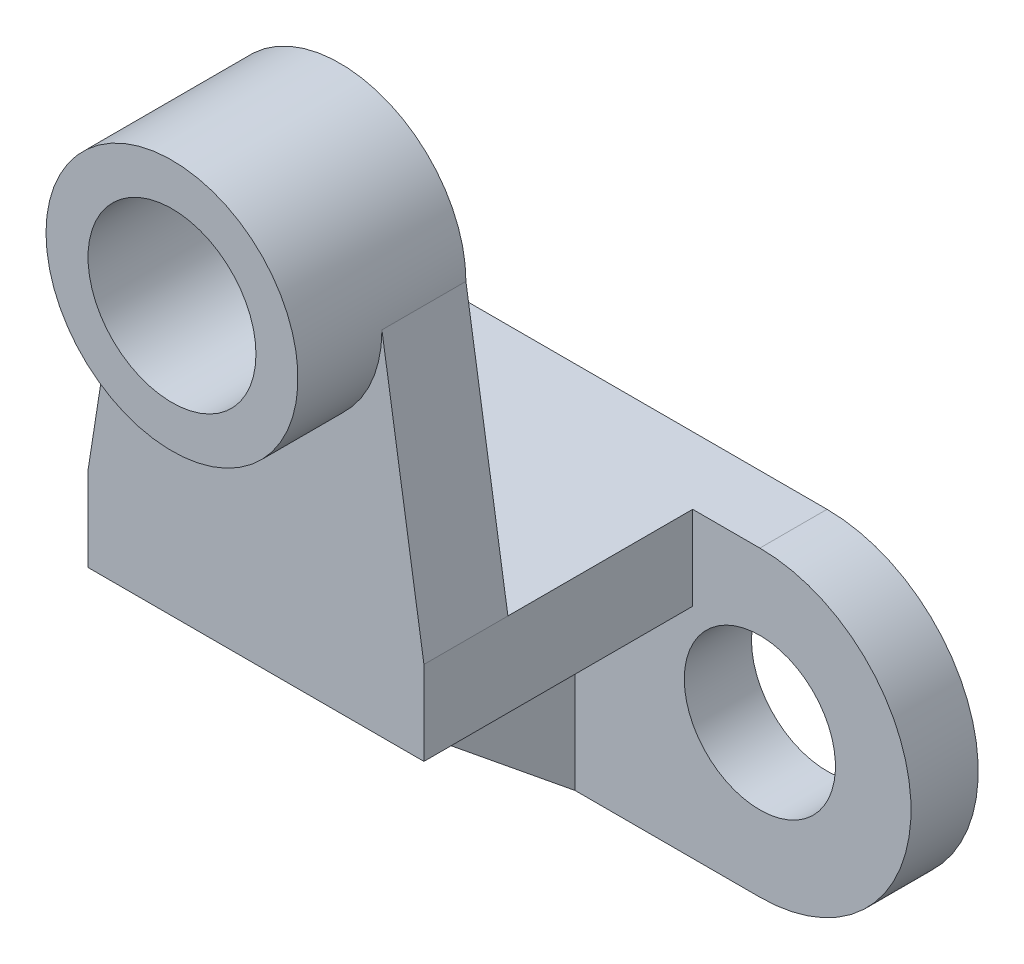
from build123d import *

# Parameters (mm, degrees)
BOSS_EXTRUDE2_DEPTH = 8
SKETCH5_R           = 9
CUT_EXTRUDE2_DEPTH  = 8
BOSS_EXTRUDE3_DEPTH = 32
CUT_EXTRUDE3_DEPTH  = 12
SKETCH8_W           = 40
SKETCH8_H           = 10
BOSS_EXTRUDE4_DEPTH = 32
SKETCH10_R          = 15
BOSS_EXTRUDE5_DEPTH = 20
CUT_EXTRUDE4_DEPTH  = 10
CUT_EXTRUDE5_DEPTH  = 10
SKETCH14_R          = 10
CUT_EXTRUDE6_DEPTH  = 20


with BuildPart() as part:
    # Sketch1 → Boss-Extrude2 (new body)
    with BuildSketch(Plane.XY):
        with BuildLine():
            Line((0, 0), (56, 0))
            ThreePointArc((56, 0), (74, 18), (56, 36))
            Line((56, 36), (0, 36))
            ThreePointArc((0, 36), (-18, 18), (0, 0))
        make_face()
    extrude(amount=BOSS_EXTRUDE2_DEPTH)

    # Sketch5 → Cut-Extrude2 (cut)
    with BuildSketch(Plane(origin=(0, 0, 0), x_dir=(-1, 0, 0), z_dir=(0, 0, -1))):
        with Locations((0, 18)):
            Circle(SKETCH5_R)
        with Locations((-56, 18)):
            Circle(SKETCH5_R)
    extrude(amount=-CUT_EXTRUDE2_DEPTH, mode=Mode.SUBTRACT)

    # Sketch6 → Boss-Extrude3 (add)
    with BuildSketch(Plane.XY.offset(8)):
        Polygon((8, 36), (48, 36), (48, 26), (34, 26), (34, 0), (22, 0), (22, 26), (8, 26), align=None)
    extrude(amount=BOSS_EXTRUDE3_DEPTH)

    # Sketch7 → Cut-Extrude3 (cut)
    with BuildSketch(Plane(origin=(34, 0, 0), x_dir=(0, 0, -1), z_dir=(1, 0, 0))):
        Polygon((-40, 26), (-8, 0), (-40, 0), align=None)
    extrude(amount=-CUT_EXTRUDE3_DEPTH, mode=Mode.SUBTRACT)

    # Sketch8 → Boss-Extrude4 (add)
    with BuildSketch(Plane(origin=(0, 36, 0), x_dir=(1, 0, 0), z_dir=(0, 1, 0))):
        with Locations((28, -35)):
            Rectangle(SKETCH8_W, SKETCH8_H)
    extrude(amount=BOSS_EXTRUDE4_DEPTH)

    # Sketch10 → Boss-Extrude5 (add)
    with BuildSketch(Plane(origin=(0, 0, 30), x_dir=(-1, 0, 0), z_dir=(0, 0, -1))):
        with Locations((-28, 68)):
            Circle(SKETCH10_R)
    extrude(amount=-BOSS_EXTRUDE5_DEPTH)

    # Sketch11 → Cut-Extrude4 (cut)
    with BuildSketch(Plane.XY.offset(40)):
        Polygon((43, 68), (48, 36), (48, 68), align=None)
    extrude(amount=-CUT_EXTRUDE4_DEPTH, mode=Mode.SUBTRACT)

    # Sketch13 → Cut-Extrude5 (cut)
    with BuildSketch(Plane.XY.offset(40)):
        Polygon((13, 68), (8, 36), (8, 68), align=None)
    extrude(amount=-CUT_EXTRUDE5_DEPTH, mode=Mode.SUBTRACT)

    # Sketch14 → Cut-Extrude6 (cut)
    with BuildSketch(Plane.XY.offset(50)):
        with Locations((28, 68)):
            Circle(SKETCH14_R)
    extrude(amount=-CUT_EXTRUDE6_DEPTH, mode=Mode.SUBTRACT)


solid = part.part
